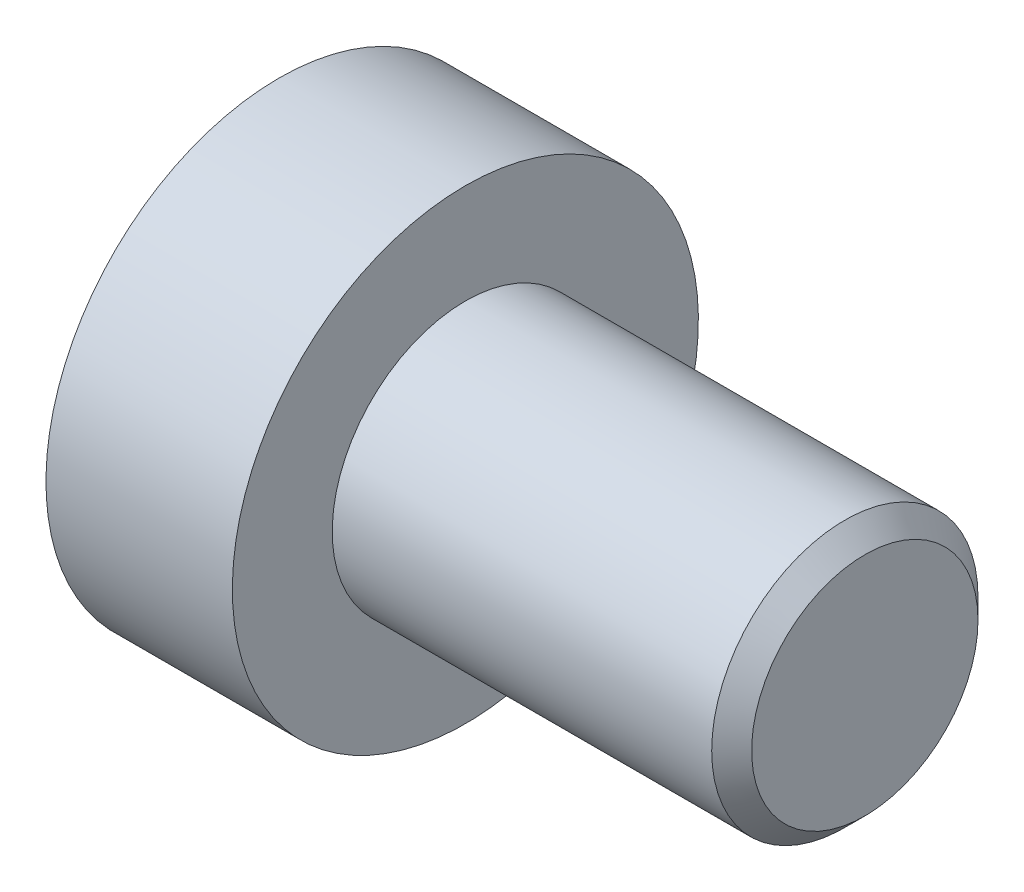
from build123d import *

# Parameters (mm, degrees)
SKETCH2_R           = 2
BOSS_EXTRUDE1_DEPTH = 6
CHAMFER1_SIZE       = 0.3
SKETCH6_W           = 2.8
SKETCH6_H           = 3.5
CUT_EXTRUDE1_DEPTH  = 1.6
SKETCH8_R           = 1.493375673
CUT_EXTRUDE2_DEPTH  = 1
CUT_EXTRUDE2_TAPER  = 45


with BuildPart() as part:
    # Sketch2 → Boss-Extrude1 (new body)
    with BuildSketch(Plane(origin=(0, 0, 0), x_dir=(0, 0, -1), z_dir=(1, 0, 0))):
        Circle(SKETCH2_R)
    extrude(amount=-BOSS_EXTRUDE1_DEPTH)

    # Chamfer1
    chamfer1_edges = [part.edges().sort_by_distance(p)[0] for p in [
        (0, 0, 2),
    ]]
    chamfer(chamfer1_edges, length=CHAMFER1_SIZE)

    # Sketch6 → Revolve1 (revolve)
    with BuildSketch(Plane.XY):
        with Locations((-7.4, 1.75)):
            Rectangle(SKETCH6_W, SKETCH6_H)
    revolve(axis=Axis((-6, 0, 0), (-1, 0, 0)))

    # Sketch7 → Cut-Extrude1 (cut)
    with BuildSketch(Plane.ZY.offset(8.8)):
        Polygon((0, 1.443375673), (-1.25, 0.721687836), (-1.25, -0.721687836), (0, -1.443375673), (1.25, -0.721687836), (1.25, 0.721687836), align=None)
    extrude(amount=-CUT_EXTRUDE1_DEPTH, mode=Mode.SUBTRACT)

    # Sketch8 → Cut-Extrude2 (cut)
    with BuildSketch(Plane.ZY.offset(8.8)):
        Circle(SKETCH8_R)
    extrude(amount=-CUT_EXTRUDE2_DEPTH, taper=CUT_EXTRUDE2_TAPER, mode=Mode.SUBTRACT)


solid = part.part
